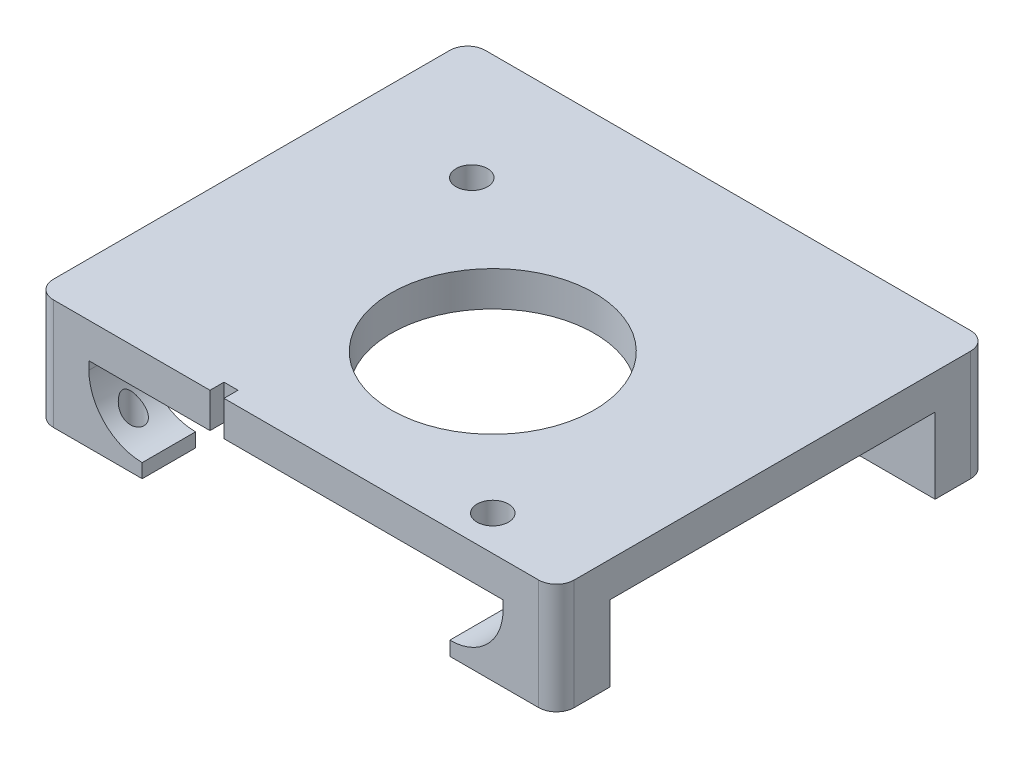
from build123d import *

# Parameters (mm, degrees)
SKETCH1_R           = 14.5
SKETCH1_R_2         = 2.25
BOSS_EXTRUDE1_DEPTH = 5
SKETCH2_W           = 7.62
SKETCH2_H           = 7.62
BOSS_EXTRUDE2_DEPTH = 10.795
SKETCH4_W           = 7.62
SKETCH4_H           = 7.62
SKETCH4_R           = 1.524
BOSS_EXTRUDE3_DEPTH = 2
BOSS_EXTRUDE4_START = -7.62
BOSS_EXTRUDE4_DEPTH = 7.62
BOSS_EXTRUDE5_START = -7.62
BOSS_EXTRUDE5_DEPTH = 7.62
SKETCH4_2_R         = 1.524
CUT_EXTRUDE1_DEPTH  = 10.795
FILLET1_R           = 2.54


with BuildPart() as part:
    # Sketch1 → Boss-Extrude1 (new body)
    with BuildSketch(Plane(origin=(0, 0, 0), x_dir=(1, 0, 0), z_dir=(0, 1, 0))):
        Polygon((-40.324, -25), (-15.4, -25), (-15.4, -23), (-13.4, -23), (-13.4, -25), (34.098, -25), (34.098, 36.722), (-40.324, 36.722), align=None)
        Circle(SKETCH1_R, mode=Mode.SUBTRACT)
        with Locations((-23, 20)):
            Circle(SKETCH1_R_2, mode=Mode.SUBTRACT)
        with Locations((20, -20)):
            Circle(SKETCH1_R_2, mode=Mode.SUBTRACT)
    extrude(amount=BOSS_EXTRUDE1_DEPTH)

    # Sketch2 → Boss-Extrude2 (add)
    with BuildSketch(Plane.XZ):
        with Locations((-36.514, 21.19)):
            Rectangle(SKETCH2_W, SKETCH2_H)
        with Locations((30.288, 21.19)):
            Rectangle(SKETCH2_W, SKETCH2_H)
        with Locations((30.288, -32.912)):
            Rectangle(SKETCH2_W, SKETCH2_H)
        with Locations((-36.514, -32.912)):
            Rectangle(SKETCH2_W, SKETCH2_H)
    extrude(amount=BOSS_EXTRUDE2_DEPTH)

    # Sketch4 → Boss-Extrude3 (add)
    with BuildSketch(Plane.XZ.offset(10.795)):
        with Locations((-28.894, 21.19)):
            Rectangle(SKETCH4_W, SKETCH4_H)
        with Locations((-30.164, 21.19)):
            Circle(SKETCH4_R, mode=Mode.SUBTRACT)
        with Locations((-28.894, -32.912)):
            Rectangle(SKETCH4_W, SKETCH4_H)
        with Locations((-30.164, -32.912)):
            Circle(SKETCH4_R, mode=Mode.SUBTRACT)
        with Locations((22.668, -32.912)):
            Rectangle(SKETCH4_W, SKETCH4_H)
        with Locations((23.938, -32.912)):
            Circle(SKETCH4_R, mode=Mode.SUBTRACT)
        with Locations((22.668, 21.19)):
            Rectangle(SKETCH4_W, SKETCH4_H)
        with Locations((23.938, 21.19)):
            Circle(SKETCH4_R, mode=Mode.SUBTRACT)
    extrude(amount=-BOSS_EXTRUDE3_DEPTH)

    # Sketch5 → Boss-Extrude4 (add)
    with BuildSketch(Plane.XY.offset(25).offset(BOSS_EXTRUDE4_START)):
        with BuildLine():
            Line((-25.084, -8.795), (-32.704, -8.795))
            Line((-32.704, -8.795), (-32.704, -1.175))
            ThreePointArc((-32.704, -1.175), (-30.472153673, -6.563153673), (-25.084, -8.795))
        make_face()
        with BuildLine():
            Line((18.858, -8.795), (26.478, -8.795))
            Line((26.478, -8.795), (26.478, -1.175))
            ThreePointArc((26.478, -1.175), (24.246153673, -6.563153673), (18.858, -8.795))
        make_face()
    extrude(amount=BOSS_EXTRUDE4_DEPTH)

    # Sketch6 → Boss-Extrude5 (add)
    with BuildSketch(Plane(origin=(0, 0, -36.722), x_dir=(-1, 0, 0), z_dir=(0, 0, -1)).offset(BOSS_EXTRUDE5_START)):
        with BuildLine():
            Line((-26.478, -8.795), (-26.478, -1.175))
            ThreePointArc((-26.478, -1.175), (-24.246153673, -6.563153673), (-18.858, -8.795))
            Line((-18.858, -8.795), (-26.478, -8.795))
        make_face()
        with BuildLine():
            Line((32.704, -8.795), (32.704, -1.175))
            ThreePointArc((32.704, -1.175), (30.472153673, -6.563153673), (25.084, -8.795))
            Line((25.084, -8.795), (32.704, -8.795))
        make_face()
    extrude(amount=BOSS_EXTRUDE5_DEPTH)

    # Sketch4_2 → Cut-Extrude1 (cut)
    with BuildSketch(Plane.XZ.offset(10.795)):
        with Locations((23.938, 21.19)):
            Circle(SKETCH4_2_R)
        with Locations((-30.164, -32.912)):
            Circle(SKETCH4_2_R)
        with Locations((-30.164, 21.19)):
            Circle(SKETCH4_2_R)
        with Locations((23.938, -32.912)):
            Circle(SKETCH4_2_R)
    extrude(amount=-CUT_EXTRUDE1_DEPTH, mode=Mode.SUBTRACT)

    # Fillet1
    fillet1_edges = [part.edges().sort_by_distance(p)[0] for p in [
        (-40.324, -2.8975, 25),
        (-40.324, -2.8975, -36.722),
        (34.098, -2.8975, -36.722),
        (34.098, -2.8975, 25),
    ]]
    fillet(fillet1_edges, radius=FILLET1_R)


solid = part.part
